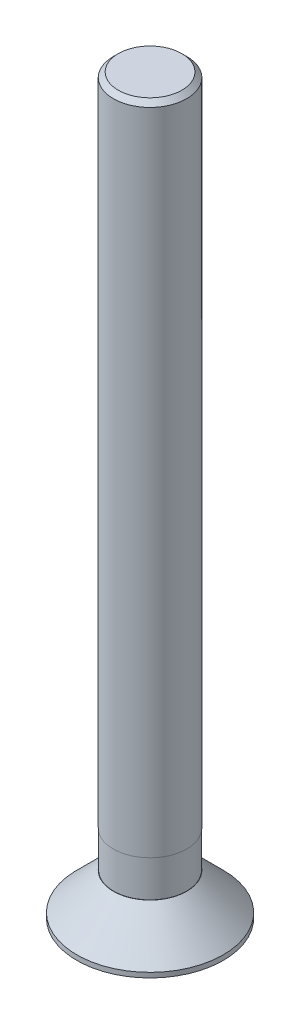
from build123d import *

# Parameters (mm, degrees)
CHAMFER1_SIZE   = 0.2
HEX_DEPTH_DEPTH = 1.2
SKETCH4_R       = 1
SKETCH3_R       = 1.154700538


with BuildPart() as part:
    # Sketch1 → Revolve1 (revolve)
    with BuildSketch(Plane.XY):
        Polygon((0, -1.873883868), (-3, -1.873883868), (-3, -1.673883868), (-1.5, -0.173883868), (-1.49, -0.173883868), (-1.49, 1.326116132), (-1.5, 1.326116132), (-1.5, 28.126116132), (0, 28.126116132), align=None)
    revolve(axis=Axis((0, 0, 0), (0, 1, 0)))

    # Chamfer1
    chamfer1_edges = [part.edges().sort_by_distance(p)[0] for p in [
        (1.5, 28.126116132, 0),
    ]]
    chamfer(chamfer1_edges, length=CHAMFER1_SIZE)

    # Sketch2 → hex depth (cut)
    with BuildSketch(Plane.XZ.offset(1.873883868)):
        Polygon((1.154700538, 0), (0.577350269, 1), (-0.577350269, 1), (-1.154700538, 0), (-0.577350269, -1), (0.577350269, -1), align=None)
    extrude(amount=-HEX_DEPTH_DEPTH, mode=Mode.SUBTRACT)

    # Sketch4 → hex corner cut section 0
    with BuildSketch(Plane(origin=(0, -1.673883868, 0), x_dir=(1, 0, 0), z_dir=(0, 1, 0))):
        Circle(SKETCH4_R)
    # Sketch3 → hex corner cut section 1
    with BuildSketch(Plane.XZ.offset(1.873883868)):
        Circle(SKETCH3_R)
    loft(mode=Mode.SUBTRACT)


solid = part.part
